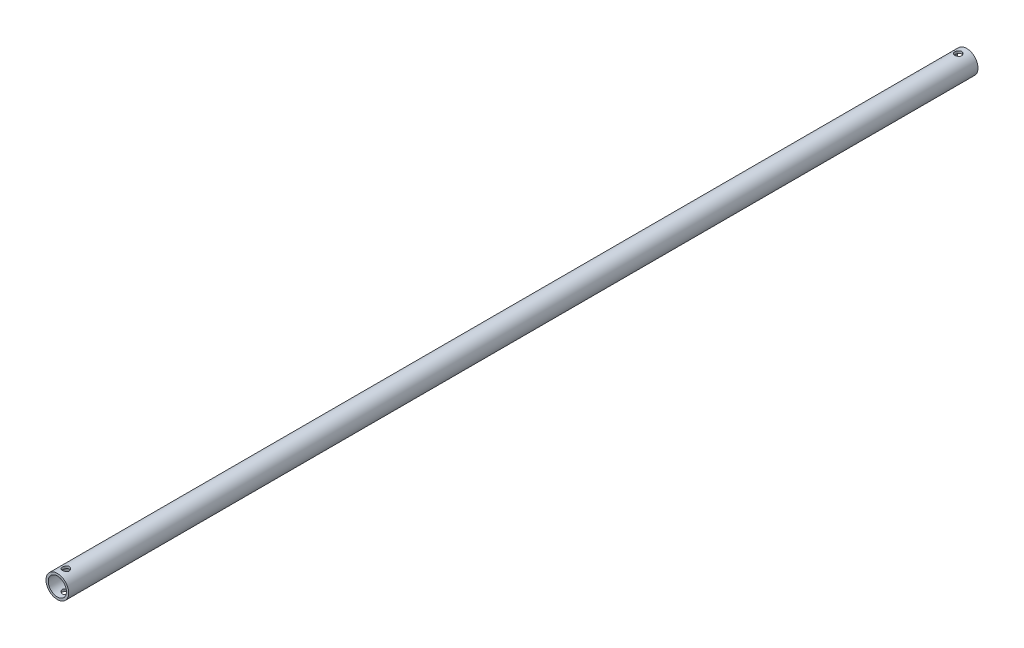
from build123d import *

# Parameters (mm, degrees)
SZKIC1_R                    = 10
DODANIE_WYCI_GNI_CIE2_DEPTH = 400
SZKIC3_R                    = 8
WYTNIJ_WYCI_GNI_CIE1_DEPTH  = 801
SZKIC4_R                    = 3
WYTNIJ_WYCI_GNI_CIE2_DEPTH  = 11


with BuildPart() as part:
    # Szkic1 → Dodanie-wyciągnięcie2 (new body, symmetric)
    with BuildSketch(Plane.XY):
        Circle(SZKIC1_R)
    extrude(amount=DODANIE_WYCI_GNI_CIE2_DEPTH, both=True)

    # Szkic3 → Wytnij-wyciągnięcie1 (cut, through all)
    with BuildSketch(Plane.XY.offset(400)):
        Circle(SZKIC3_R)
    extrude(amount=-WYTNIJ_WYCI_GNI_CIE1_DEPTH, mode=Mode.SUBTRACT)

    # Szkic4 → Wytnij-wyciągnięcie2 (cut, symmetric)
    with BuildSketch(Plane(origin=(0, 0, 0), x_dir=(1, 0, 0), z_dir=(0, 1, 0))):
        with Locations((0, -392.5)):
            Circle(SZKIC4_R)
    wytnij_wyci_gni_cie2 = extrude(amount=WYTNIJ_WYCI_GNI_CIE2_DEPTH, both=True, mode=Mode.SUBTRACT)

    # Lustro1: Wytnij-wyciągnięcie2 across plane
    add(wytnij_wyci_gni_cie2.mirror(Plane(origin=(0, 0, 0), x_dir=(1, 0, 0), z_dir=(0, 0, -1))), mode=Mode.SUBTRACT)


solid = part.part
